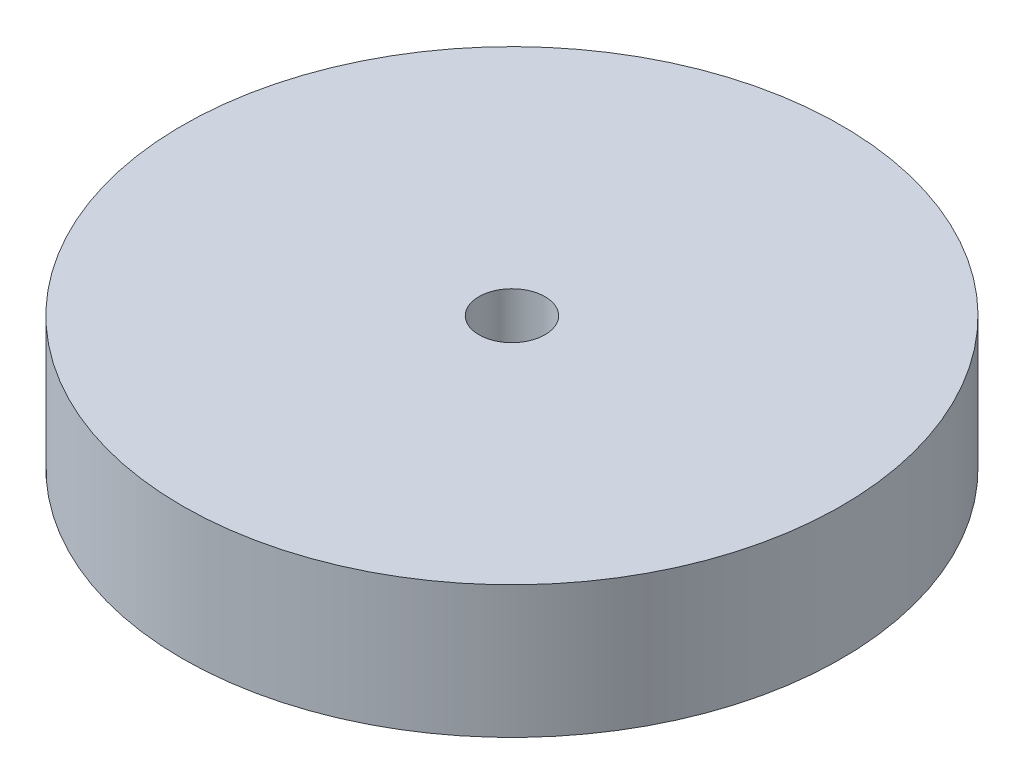
from build123d import *

# Parameters (mm, degrees)
SKETCH1_R           = 12.662852008
SKETCH1_R_2         = 1.27
BOSS_EXTRUDE2_DEPTH = 5.08


with BuildPart() as part:
    # Sketch1 → Boss-Extrude2 (new body)
    with BuildSketch(Plane(origin=(0, 0, 0), x_dir=(1, 0, 0), z_dir=(0, 1, 0))):
        Circle(SKETCH1_R)
        Circle(SKETCH1_R_2, mode=Mode.SUBTRACT)
    extrude(amount=BOSS_EXTRUDE2_DEPTH)


solid = part.part
